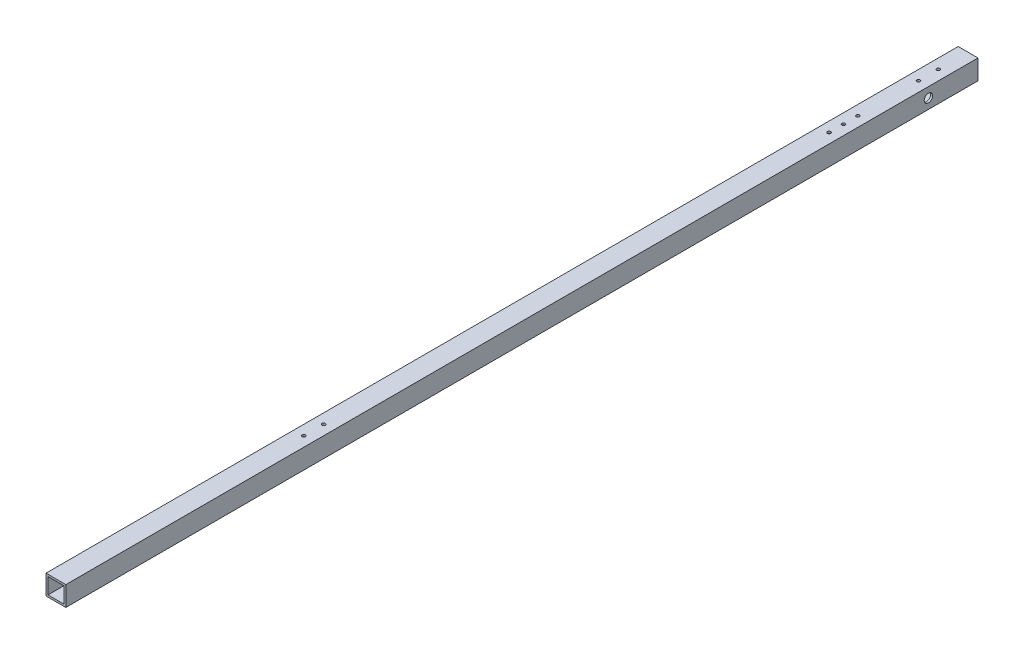
from build123d import *

# Parameters (mm, degrees)
SKETCH_1_W           = 20
SKETCH_1_H           = 20
SKETCH_1_W_2         = 16
SKETCH_1_H_2         = 16
EXTRUDE_1_DEPTH      = 970
CUT_EXTRUDE_1_DEPTH  = 20
CUT_EXTRUDE_2_DEPTH  = 10
SKETCH_6_W           = 27.825743136
SKETCH_6_H           = 21.841712354
CUT_EXTRUDE_8_DEPTH  = 50
SKETCH_9_R           = 1
CUT_EXTRUDE_9_DEPTH  = 10
M4X0_7_3_D           = 3.3
M4X0_7_2_D           = 3.3
M4X0_7_7_D           = 3.3
M4X0_7_7_DEPTH       = 11.5
M4X0_7_7_TIP         = 0.991420021
M4X0_7_9_D           = 3.3
M4X0_7_9_DEPTH       = 11.5
M4X0_7_9_TIP         = 0.991420021
SKETCH_26_R          = 1
CUT_EXTRUDE_10_DEPTH = 10
M4X0_7_10_D          = 3.3
M4X0_7_10_DEPTH      = 11.5
M4X0_7_10_TIP        = 0.991420021


with BuildPart() as part:
    # ｽｹｯﾁ1 → ﾎﾞｽ - 押し出し1 (new body)
    with BuildSketch(Plane.XY):
        Rectangle(SKETCH_1_W, SKETCH_1_H)
        Rectangle(SKETCH_1_W_2, SKETCH_1_H_2, mode=Mode.SUBTRACT)
    extrude(amount=EXTRUDE_1_DEPTH)

    # ｽｹｯﾁ2 → ｶｯﾄ - 押し出し1 (cut)
    with BuildSketch(Plane(origin=(10, 0, 0), x_dir=(0, 0, -1), z_dir=(1, 0, 0))):
        with BuildLine():
            ThreePointArc((-45.75, 0), (-50, 4.25), (-54.25, 0))
            Line((-54.25, 0), (-50, 0))
            Line((-50, 0), (-45.75, 0))
        make_face()
        with BuildLine():
            Line((-50, 0), (-54.25, 0))
            ThreePointArc((-54.25, 0), (-50, -4.25), (-45.75, 0))
            Line((-45.75, 0), (-50, 0))
        make_face()
    extrude(amount=-CUT_EXTRUDE_1_DEPTH, mode=Mode.SUBTRACT)

    # ｽｹｯﾁ3 → ｶｯﾄ - 押し出し2 (cut)
    with BuildSketch(Plane(origin=(0, 10, 0), x_dir=(1, 0, 0), z_dir=(0, 1, 0))):
        with BuildLine():
            ThreePointArc((0, -649), (-1, -650), (0, -651))
            Line((0, -651), (0, -650))
            Line((0, -650), (0, -649))
        make_face()
        with BuildLine():
            Line((0, -650), (0, -651))
            ThreePointArc((0, -651), (0.707106781, -650.707106781), (1, -650))
            ThreePointArc((1, -650), (0.707106781, -649.292893219), (0, -649))
            Line((0, -649), (0, -650))
        make_face()
        with BuildLine():
            ThreePointArc((0, -669), (-1, -670), (0, -671))
            Line((0, -671), (0, -670))
            Line((0, -670), (0, -669))
        make_face()
        with BuildLine():
            Line((0, -670), (0, -671))
            ThreePointArc((0, -671), (0.707106781, -670.707106781), (1, -670))
            ThreePointArc((1, -670), (0.707106781, -669.292893219), (0, -669))
            Line((0, -669), (0, -670))
        make_face()
    extrude(amount=-CUT_EXTRUDE_2_DEPTH, mode=Mode.SUBTRACT)

    # ｽｹｯﾁ6 → ｶｯﾄ - 押し出し8 (cut)
    with BuildSketch(Plane.XY.offset(970)):
        Rectangle(SKETCH_6_W, SKETCH_6_H)
    extrude(amount=-CUT_EXTRUDE_8_DEPTH, mode=Mode.SUBTRACT)

    # ｽｹｯﾁ9 → ｶｯﾄ - 押し出し9 (cut)
    with BuildSketch(Plane(origin=(0, 10, 0), x_dir=(1, 0, 0), z_dir=(0, 1, 0))):
        with Locations((0, -30)):
            Circle(SKETCH_9_R)
        with Locations((0, -50)):
            Circle(SKETCH_9_R)
    extrude(amount=-CUT_EXTRUDE_9_DEPTH, mode=Mode.SUBTRACT)

    # M4x0.7 ねじ穴3 (through all)
    with Locations(Plane(origin=(0, 10, 111.21), x_dir=(1, 0, 0), z_dir=(0, 1, 0))):
        with Locations((0, 0), (0, -29)):
            Hole(M4X0_7_3_D / 2)

    # M4x0.7 ねじ穴2 (through all)
    with Locations(Plane(origin=(0, 10, 125.71), x_dir=(1, 0, 0), z_dir=(0, 1, 0))):
        with Locations((0, 0)):
            Hole(M4X0_7_2_D / 2)

    # M4x0.7 ねじ穴7
    with Locations(Plane(origin=(0, 10, 650), x_dir=(1, 0, 0), z_dir=(0, 1, 0))):
        with Locations((0, 0), (0, -20)):
            Hole(M4X0_7_7_D / 2, depth=M4X0_7_7_DEPTH)
            with Locations((0, 0, -(M4X0_7_7_DEPTH + M4X0_7_7_TIP / 2))):  # 118° drill point
                Cone(0, M4X0_7_7_D / 2, M4X0_7_7_TIP, mode=Mode.SUBTRACT)

    # M4x0.7 ねじ穴9
    with Locations(Plane(origin=(0, 10, 30), x_dir=(1, 0, 0), z_dir=(0, 1, 0))):
        with Locations((0, 0), (0, -20)):
            Hole(M4X0_7_9_D / 2, depth=M4X0_7_9_DEPTH)
            with Locations((0, 0, -(M4X0_7_9_DEPTH + M4X0_7_9_TIP / 2))):  # 118° drill point
                Cone(0, M4X0_7_9_D / 2, M4X0_7_9_TIP, mode=Mode.SUBTRACT)

    # ｽｹｯﾁ26 → ｶｯﾄ - 押し出し10 (cut)
    with BuildSketch(Plane.ZY.offset(10)):
        with Locations((40, 0)):
            Circle(SKETCH_26_R)
        with Locations((710, 0)):
            Circle(SKETCH_26_R)
        with Locations((730, 0)):
            Circle(SKETCH_26_R)
    extrude(amount=-CUT_EXTRUDE_10_DEPTH, mode=Mode.SUBTRACT)

    # M4x0.7 ねじ穴10
    with Locations(Plane(origin=(-10, 0, 730), x_dir=(0, 0, -1), z_dir=(-1, 0, 0))):
        with Locations((0, 0), (20, 0), (690, 0)):
            Hole(M4X0_7_10_D / 2, depth=M4X0_7_10_DEPTH)
            with Locations((0, 0, -(M4X0_7_10_DEPTH + M4X0_7_10_TIP / 2))):  # 118° drill point
                Cone(0, M4X0_7_10_D / 2, M4X0_7_10_TIP, mode=Mode.SUBTRACT)


solid = part.part
